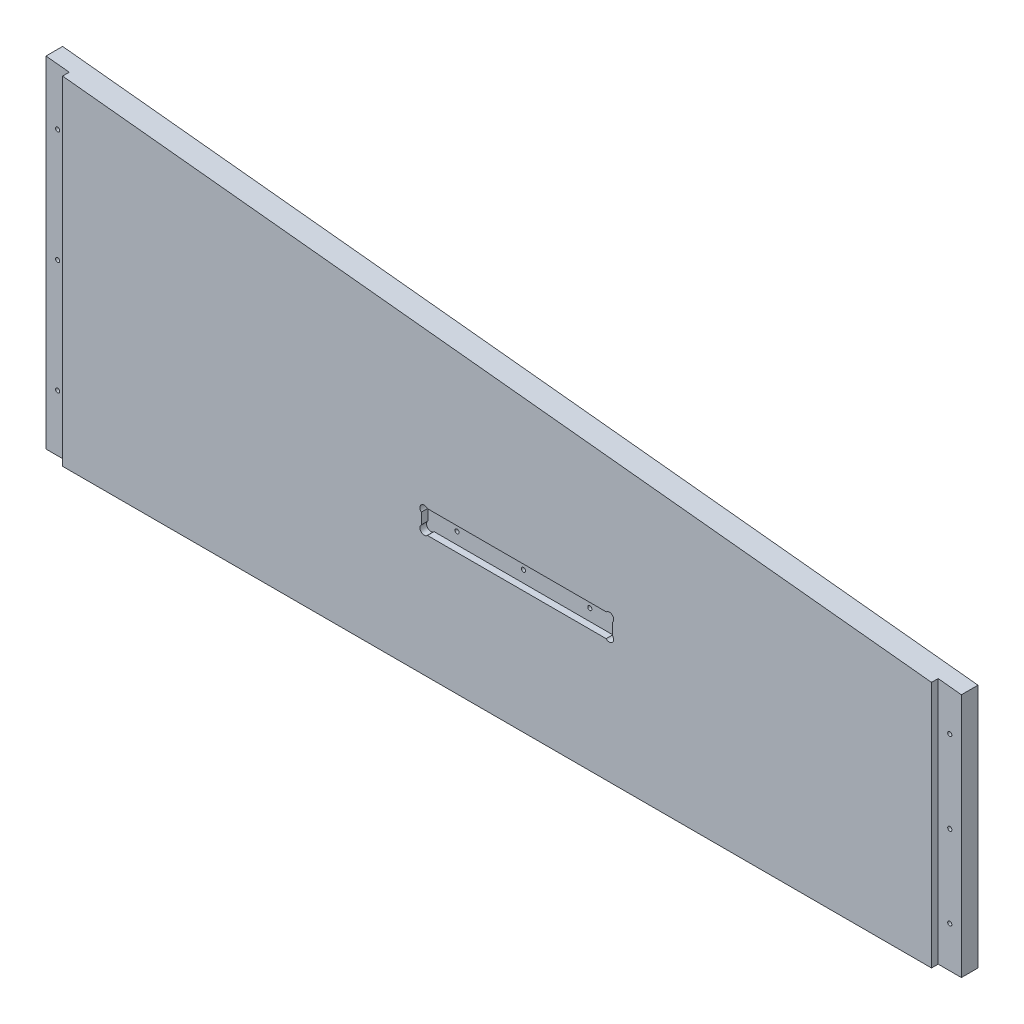
from build123d import *

# Parameters (mm, degrees)
HEADSIDERIGHT_THICKNESS_DEPTH = 17.78
EXTRUDE4_DEPTH                = 12.7
SKETCH8_R                     = 1.5875
CUT_EXTRUDE4_DEPTH            = 17.78
SKETCH9_W                     = 146.050000002
SKETCH9_H                     = 17.78
CUT_EXTRUDE5_DEPTH            = 5.08
SKETCH11_R                    = 3.302
CUT_EXTRUDE6_DEPTH            = 5.08


with BuildPart() as part:
    # HeadSideRightOutline → HeadSideRight_Thickness (new body)
    with BuildSketch(Plane.XY):
        Polygon((174.9425, -6013.45), (839.47, -6013.45), (839.47, -5824.270396825), (174.9425, -5754.954603175), align=None)
    extrude(amount=-HEADSIDERIGHT_THICKNESS_DEPTH)

    # Sketch10 → Extrude4 (add)
    with BuildSketch(Plane(origin=(0, 0, -17.78), x_dir=(-1, 0, 0), z_dir=(0, 0, -1))):
        Polygon((-174.9425, -6013.45), (-157.1625, -6013.45), (-157.1625, -5753.1), (-174.9425, -5754.954603175), align=None)
        Polygon((-839.47, -6013.45), (-857.25, -6013.45), (-857.25, -5826.125), (-839.47, -5824.270396825), align=None)
    extrude(amount=-EXTRUDE4_DEPTH)

    # Sketch8 → Cut-Extrude4 (cut)
    with BuildSketch(Plane.XY):
        with Locations((166.0525, -5970.212883599)):
            Circle(SKETCH8_R)
        with Locations((166.0525, -5883.738650795)):
            Circle(SKETCH8_R)
        with Locations((166.0525, -5797.264417991)):
            Circle(SKETCH8_R)
        with Locations((848.36, -5982.074616401)):
            Circle(SKETCH8_R)
        with Locations((848.36, -5919.323849205)):
            Circle(SKETCH8_R)
        with Locations((848.36, -5856.573082009)):
            Circle(SKETCH8_R)
        with Locations((471.4875, -5910.834)):
            Circle(SKETCH8_R)
        with Locations((522.2875, -5910.834)):
            Circle(SKETCH8_R)
        with Locations((573.0875, -5910.834)):
            Circle(SKETCH8_R)
    extrude(amount=-CUT_EXTRUDE4_DEPTH, mode=Mode.SUBTRACT)

    # Sketch9 → Cut-Extrude5 (cut)
    with BuildSketch(Plane.XY):
        with Locations((522.2875, -5910.834)):
            Rectangle(SKETCH9_W, SKETCH9_H)
    extrude(amount=-CUT_EXTRUDE5_DEPTH, mode=Mode.SUBTRACT)

    # Sketch11 → Cut-Extrude6 (cut)
    with BuildSketch(Plane.XY):
        with Locations((451.507564029, -5904.18906403)):
            Circle(SKETCH11_R)
        with Locations((451.507564029, -5917.47893597)):
            Circle(SKETCH11_R)
        with Locations((593.067435971, -5917.47893597)):
            Circle(SKETCH11_R)
        with Locations((593.067435971, -5904.18906403)):
            Circle(SKETCH11_R)
    extrude(amount=-CUT_EXTRUDE6_DEPTH, mode=Mode.SUBTRACT)


solid = part.part
